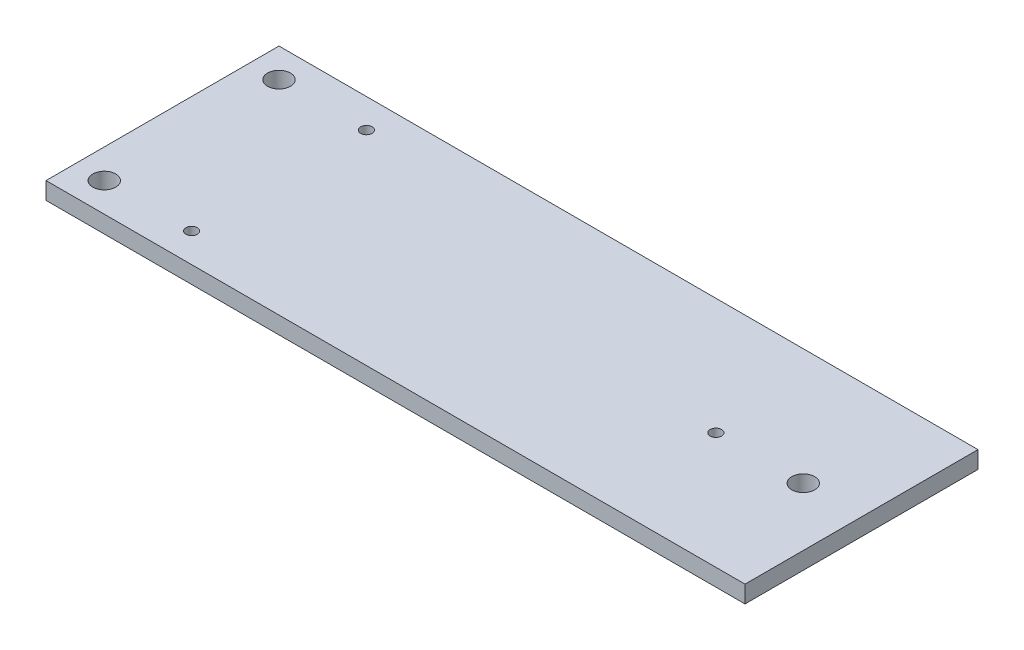
from build123d import *

# Parameters (mm, degrees)
SKETCH1_W           = 60.96
SKETCH1_H           = 20.32
SKETCH1_R           = 1
SKETCH1_R_2         = 0.5
BOSS_EXTRUDE1_DEPTH = 1.5


with BuildPart() as part:
    # Sketch1 → Boss-Extrude1 (new body)
    with BuildSketch(Plane(origin=(0, 0, 0), x_dir=(1, 0, 0), z_dir=(0, 1, 0))):
        with Locations((30.48, 10.16)):
            Rectangle(SKETCH1_W, SKETCH1_H)
        with Locations(Location((2.54, 2.54, 0), (0, 0, 270))):  # turned: the seam where the file's is
            Circle(SKETCH1_R, mode=Mode.SUBTRACT)
        with Locations(Location((55.88, 10.16, 0), (0, 0, 270))):  # turned: the seam where the file's is
            Circle(SKETCH1_R, mode=Mode.SUBTRACT)
        with Locations(Location((2.54, 17.78, 0), (0, 0, 90))):  # turned: the seam where the file's is
            Circle(SKETCH1_R, mode=Mode.SUBTRACT)
        with Locations(Location((10.16, 2.54, 0), (0, 0, 270))):  # turned: the seam where the file's is
            Circle(SKETCH1_R_2, mode=Mode.SUBTRACT)
        with Locations(Location((48.26, 10.16, 0), (0, 0, 270))):  # turned: the seam where the file's is
            Circle(SKETCH1_R_2, mode=Mode.SUBTRACT)
        with Locations(Location((10.16, 17.78, 0), (0, 0, 90))):  # turned: the seam where the file's is
            Circle(SKETCH1_R_2, mode=Mode.SUBTRACT)
    extrude(amount=BOSS_EXTRUDE1_DEPTH)


solid = part.part
